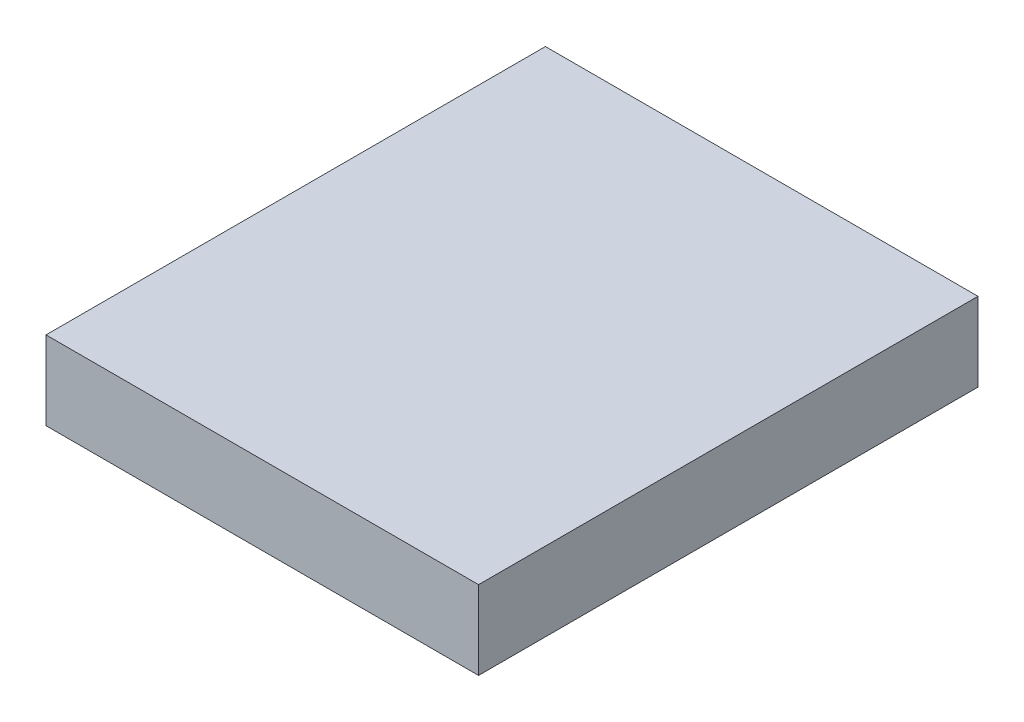
from build123d import *

# Parameters (mm, degrees)
BOSS_EXTRUDE1_DEPTH = 38.1
SKETCH1_4_R         = 1.75
BOSS_EXTRUDE3_DEPTH = 7.5
SKETCH1_5_R         = 1.75
CUT_EXTRUDE1_DEPTH  = 1.75


with BuildPart() as part:
    # Sketch1 → Boss-Extrude1 (new, symmetric)
    with BuildSketch(Plane.XY):
        Polygon((-7.875, 21.53615257), (7.875, 21.53615257), (33, 21.53615257), (33, 33.53615257), (-33, 33.53615257), (-33, 21.53615257), align=None)
    extrude(amount=BOSS_EXTRUDE1_DEPTH, both=True)

    # Sketch1_4 → Boss-Extrude3 (add, symmetric)
    with BuildSketch(Plane.XY):
        with BuildLine():
            ThreePointArc((1.951498019, 5.12615257), (3.835867687, 3.947771767), (6.019900654, 3.53615257))
            Line((6.019900654, 3.53615257), (6.125, 3.53615257))
            ThreePointArc((6.125, 3.53615257), (7.362436867, 4.048715703), (7.875, 5.28615257))
            Line((7.875, 5.28615257), (7.875, 21.53615257))
            Line((7.875, 21.53615257), (-7.875, 21.53615257))
            Line((-7.875, 21.53615257), (-7.875, 5.28615257))
            ThreePointArc((-7.875, 5.28615257), (-7.362436867, 4.048715703), (-6.125, 3.53615257))
            Line((-6.125, 3.53615257), (-6.019900654, 3.53615257))
            ThreePointArc((-6.019900654, 3.53615257), (-3.835867687, 3.947771767), (-1.951498019, 5.12615257))
            Line((-1.951498019, 5.12615257), (-2.37323487, 4.737083337))
            ThreePointArc((-2.37323487, 4.737083337), (0, 5.664583337), (2.37323487, 4.737083337))
            Line((2.37323487, 4.737083337), (1.951498019, 5.12615257))
        make_face()
        with Locations((-5.656854249, 5.656854249)):
            Circle(SKETCH1_4_R, mode=Mode.SUBTRACT)
        with Locations((5.656854249, 5.656854249)):
            Circle(SKETCH1_4_R, mode=Mode.SUBTRACT)
    extrude(amount=BOSS_EXTRUDE3_DEPTH, both=True)

    # Sketch1_5 → Cut-Extrude1 (cut, symmetric)
    with BuildSketch(Plane.XY):
        with BuildLine():
            ThreePointArc((1.951498019, 5.12615257), (3.835867687, 3.947771767), (6.019900654, 3.53615257))
            Line((6.019900654, 3.53615257), (6.125, 3.53615257))
            ThreePointArc((6.125, 3.53615257), (7.362436867, 4.048715703), (7.875, 5.28615257))
            Line((7.875, 5.28615257), (7.875, 7.68012858))
            ThreePointArc((7.875, 7.68012858), (0, 11), (-7.875, 7.68012858))
            Line((-7.875, 7.68012858), (-7.875, 5.28615257))
            ThreePointArc((-7.875, 5.28615257), (-7.362436867, 4.048715703), (-6.125, 3.53615257))
            Line((-6.125, 3.53615257), (-6.019900654, 3.53615257))
            ThreePointArc((-6.019900654, 3.53615257), (-3.835867687, 3.947771767), (-1.951498019, 5.12615257))
            Line((-1.951498019, 5.12615257), (-2.37323487, 4.737083337))
            ThreePointArc((-2.37323487, 4.737083337), (0, 5.664583337), (2.37323487, 4.737083337))
            Line((2.37323487, 4.737083337), (1.951498019, 5.12615257))
        make_face()
        with Locations((-5.656854249, 5.656854249)):
            Circle(SKETCH1_5_R, mode=Mode.SUBTRACT)
        with Locations((5.656854249, 5.656854249)):
            Circle(SKETCH1_5_R, mode=Mode.SUBTRACT)
    extrude(amount=CUT_EXTRUDE1_DEPTH, both=True, mode=Mode.SUBTRACT)


solid = part.part
